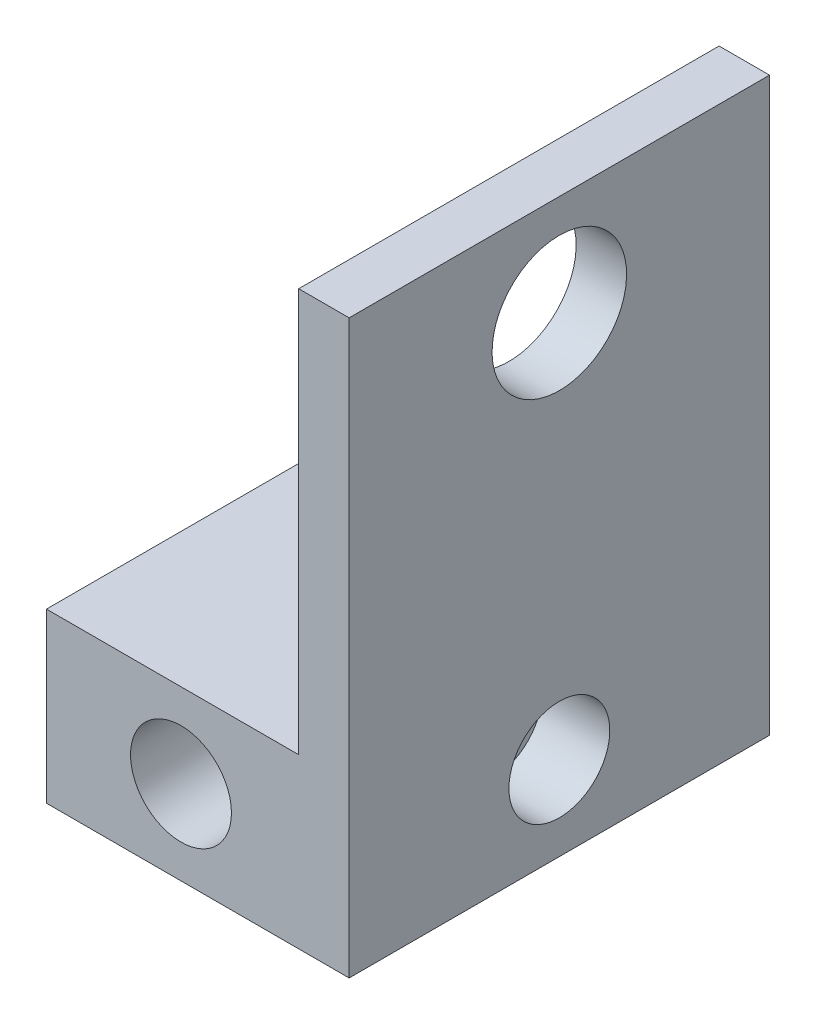
from build123d import *

# Parameters (mm, degrees)
ESQUISSE1_W             = 18
ESQUISSE1_H             = 34
BOSS_EXTRU_1_DEPTH      = 25
ESQUISSE2_R             = 3
ESQUISSE2_W             = 15
ESQUISSE2_H             = 24
ENL_V_MAT_EXTRU_1_DEPTH = 26
ESQUISSE3_R             = 3
ENL_V_MAT_EXTRU_2_DEPTH = 4
ESQUISSE4_R             = 4
ENL_V_MAT_EXTRU_3_DEPTH = 19


with BuildPart() as part:
    # Esquisse1 → Boss.-Extru.1 (new body)
    with BuildSketch(Plane.XY):
        with Locations((9, -17)):
            Rectangle(ESQUISSE1_W, ESQUISSE1_H)
    extrude(amount=BOSS_EXTRU_1_DEPTH)

    # Esquisse2 → Enlèv. mat.-Extru.1 (cut, through all)
    with BuildSketch(Plane.XY.offset(25)):
        with Locations((8, -29)):
            Circle(ESQUISSE2_R)
        with Locations((7.5, -12)):
            Rectangle(ESQUISSE2_W, ESQUISSE2_H)
    extrude(amount=-ENL_V_MAT_EXTRU_1_DEPTH, mode=Mode.SUBTRACT)

    # Esquisse3 → Enlèv. mat.-Extru.2 (cut)
    with BuildSketch(Plane(origin=(18, 0, 0), x_dir=(0, 0, -1), z_dir=(1, 0, 0))):
        with Locations((-12.5, -29)):
            Circle(ESQUISSE3_R)
    extrude(amount=-ENL_V_MAT_EXTRU_2_DEPTH, mode=Mode.SUBTRACT)

    # Esquisse4 → Enlèv. mat.-Extru.3 (cut, through all)
    with BuildSketch(Plane(origin=(18, 0, 0), x_dir=(0, 0, -1), z_dir=(1, 0, 0))):
        with Locations((-12.5, -6)):
            Circle(ESQUISSE4_R)
    extrude(amount=-ENL_V_MAT_EXTRU_3_DEPTH, mode=Mode.SUBTRACT)


solid = part.part
